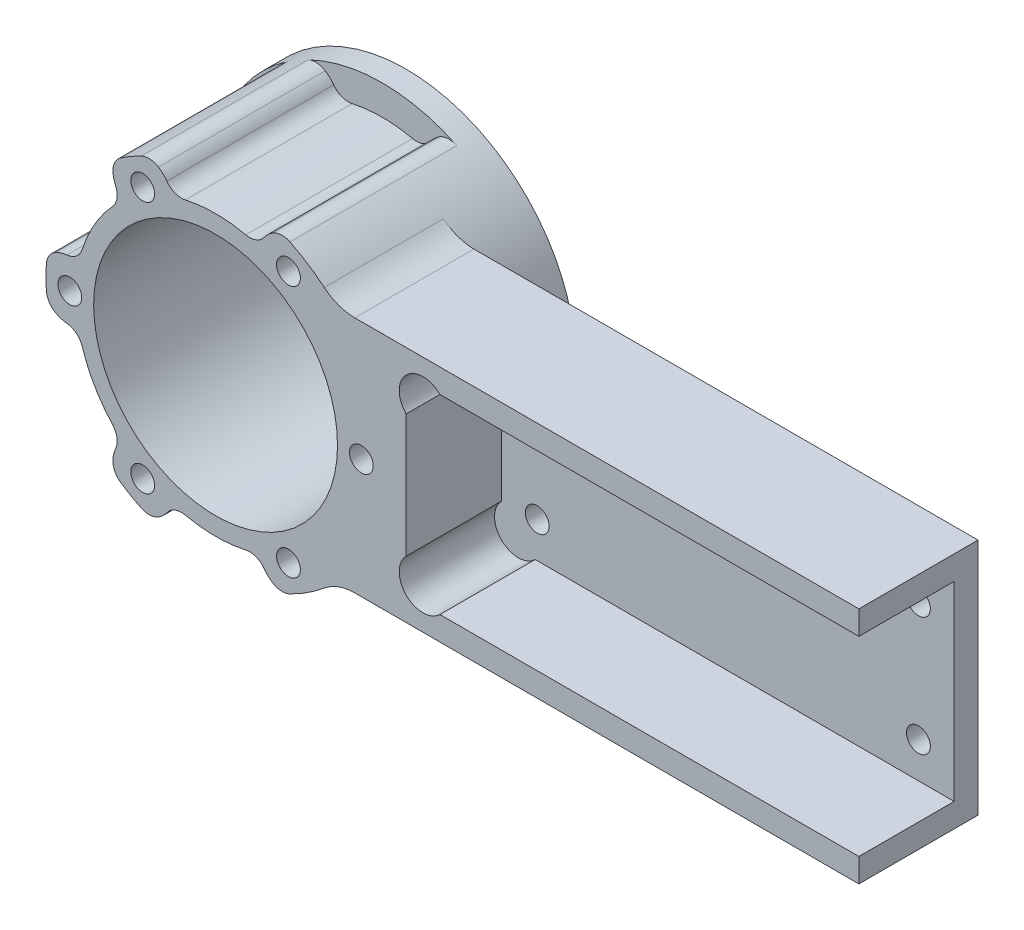
from build123d import *

# Parameters (mm, degrees)
SKETCH1_R               = 32.5
SKETCH1_W               = 120.65
SKETCH1_H               = 50.8
BOSS_EXTRUDE2_DEPTH     = 6.35
BOSS_EXTRUDE3_START     = 6.35
SKETCH1_3_R             = 32.5
BOSS_EXTRUDE3_DEPTH     = 25.4
SKETCH2_R               = 3.175
CUT_EXTRUDE1_DEPTH      = 26.4
CUT_EXTRUDE1_DEPTH_BACK = 7.35
SKETCH3_R               = 6.35
CUT_EXTRUDE2_DEPTH      = 25.4
FILLET1_R               = 12.7
SKETCH5_R               = 32.5
BOSS_EXTRUDE6_DEPTH     = 19.05
SKETCH6_R               = 32.5
SKETCH6_R_2             = 27.5
BOSS_EXTRUDE7_DEPTH     = 2.54
SKETCH9_R               = 3.175
CUT_EXTRUDE3_DEPTH      = 1
CUT_EXTRUDE3_DEPTH_BACK = 51.8
CUT_EXTRUDE4_DEPTH      = 44.45
FILLET3_R               = 4.7625


with BuildPart() as part:
    # Sketch1 → Boss-Extrude2 (new body)
    with BuildSketch(Plane.XY):
        with BuildLine():
            Line((32.171066193, 31.75), (171.45, 31.75))
            Line((171.45, 31.75), (171.45, 25.4))
            Line((171.45, 25.4), (50.8, 25.4))
            Line((50.8, 25.4), (50.8, -25.4))
            Line((50.8, -25.4), (171.45, -25.4))
            Line((171.45, -25.4), (171.45, -31.75))
            Line((171.45, -31.75), (32.171066193, -31.75))
            ThreePointArc((32.171066193, -31.75), (-45.2, 0), (32.171066193, 31.75))
        make_face()
        Circle(SKETCH1_R, mode=Mode.SUBTRACT)
        with Locations((111.125, 0)):
            Rectangle(SKETCH1_W, SKETCH1_H)
    extrude(amount=BOSS_EXTRUDE2_DEPTH)

    # Sketch1_3 → Boss-Extrude3 (add)
    with BuildSketch(Plane.XY.offset(BOSS_EXTRUDE3_START)):
        with BuildLine():
            Line((32.171066193, 31.75), (171.45, 31.75))
            Line((171.45, 31.75), (171.45, 25.4))
            Line((171.45, 25.4), (50.8, 25.4))
            Line((50.8, 25.4), (50.8, -25.4))
            Line((50.8, -25.4), (171.45, -25.4))
            Line((171.45, -25.4), (171.45, -31.75))
            Line((171.45, -31.75), (32.171066193, -31.75))
            ThreePointArc((32.171066193, -31.75), (-45.2, 0), (32.171066193, 31.75))
        make_face()
        Circle(SKETCH1_3_R, mode=Mode.SUBTRACT)
    extrude(amount=BOSS_EXTRUDE3_DEPTH)

    # Sketch2 → Cut-Extrude1 (cut, two sides)
    with BuildSketch(Plane.XY.offset(6.35)) as cut_extrude1_sk:
        with Locations((60.325, 15.875)):
            Circle(SKETCH2_R)
        with Locations((161.925, 15.875)):
            Circle(SKETCH2_R)
        with Locations((161.925, -15.875)):
            Circle(SKETCH2_R)
        with Locations((60.325, -15.875)):
            Circle(SKETCH2_R)
    extrude(amount=CUT_EXTRUDE1_DEPTH, mode=Mode.SUBTRACT)
    extrude(cut_extrude1_sk.sketch, amount=-CUT_EXTRUDE1_DEPTH_BACK, mode=Mode.SUBTRACT)

    # Sketch3 → Cut-Extrude2 (cut)
    with BuildSketch(Plane.XY.offset(31.75)):
        with Locations((55.290128061, 20.909871939)):
            Circle(SKETCH3_R)
        with Locations((55.290128061, -20.909871939)):
            Circle(SKETCH3_R)
    extrude(amount=-CUT_EXTRUDE2_DEPTH, mode=Mode.SUBTRACT)

    # Fillet1
    fillet1_edges = [part.edges().sort_by_distance(p)[0] for p in [
        (32.171066193, -31.75, 15.875),
        (32.171066193, 31.75, 15.875),
    ]]
    fillet(fillet1_edges, radius=FILLET1_R)

    # Sketch5 → Boss-Extrude6 (add)
    with BuildSketch(Plane(origin=(0, 0, 0), x_dir=(-1, 0, 0), z_dir=(0, 0, -1))):
        with BuildLine():
            ThreePointArc((-28.964426695, -34.700172712), (45.2, 0), (-28.964426695, 34.700172712))
            ThreePointArc((-28.964426695, 34.700172712), (-45.2, 0), (-28.964426695, -34.700172712))
        make_face()
        Circle(SKETCH5_R, mode=Mode.SUBTRACT)
    extrude(amount=BOSS_EXTRUDE6_DEPTH)

    # Sketch6 → Boss-Extrude7 (add)
    with BuildSketch(Plane(origin=(0, 0, -19.05), x_dir=(-1, 0, 0), z_dir=(0, 0, -1))):
        Circle(SKETCH6_R)
        Circle(SKETCH6_R_2, mode=Mode.SUBTRACT)
    extrude(amount=-BOSS_EXTRUDE7_DEPTH)

    # Sketch9 → Cut-Extrude3 (cut, two sides)
    with BuildSketch(Plane(origin=(0, 0, -19.05), x_dir=(-1, 0, 0), z_dir=(0, 0, -1))) as cut_extrude3_sk:
        with Locations((38.85, 0)):
            Circle(SKETCH9_R)
        with Locations((19.425, -33.645086937)):
            Circle(SKETCH9_R)
        with Locations((-19.425, -33.645086937)):
            Circle(SKETCH9_R)
        with Locations((-38.85, 0)):
            Circle(SKETCH9_R)
        with Locations((-19.425, 33.645086937)):
            Circle(SKETCH9_R)
        with Locations((19.425, 33.645086937)):
            Circle(SKETCH9_R)
    extrude(amount=CUT_EXTRUDE3_DEPTH, mode=Mode.SUBTRACT)
    extrude(cut_extrude3_sk.sketch, amount=-CUT_EXTRUDE3_DEPTH_BACK, mode=Mode.SUBTRACT)

    # Sketch10 → Cut-Extrude4 (cut)
    with BuildSketch(Plane.XY.offset(31.75)):
        with BuildLine():
            ThreePointArc((11.68042689, 35.384481541), (0, 37.2625), (-11.68042689, 35.384481541))
            ThreePointArc((-11.68042689, 35.384481541), (-13.931491225, 39.374420894), (-18.012469973, 41.455891324))
            ThreePointArc((-18.012469973, 41.455891324), (0, 45.2), (18.012469973, 41.455891324))
            ThreePointArc((18.012469973, 41.455891324), (13.931491225, 39.374420894), (11.68042689, 35.384481541))
        make_face()
        with BuildLine():
            ThreePointArc((-26.895620037, 36.327202244), (-27.133503141, 31.752235761), (-24.803646469, 27.807787184))
            ThreePointArc((-24.803646469, 27.807787184), (-32.270271609, 18.63125), (-36.484073359, 7.576694357))
            ThreePointArc((-36.484073359, 7.576694357), (-41.064994367, 7.622185133), (-44.90809001, 5.128689081))
            ThreePointArc((-44.90809001, 5.128689081), (-39.144348251, 22.6), (-26.895620037, 36.327202244))
        make_face()
        with BuildLine():
            ThreePointArc((-44.90809001, -5.128689081), (-41.064994367, -7.622185133), (-36.484073359, -7.576694357))
            ThreePointArc((-36.484073359, -7.576694357), (-32.270271609, -18.63125), (-24.803646469, -27.807787184))
            ThreePointArc((-24.803646469, -27.807787184), (-27.133503141, -31.752235761), (-26.895620037, -36.327202244))
            ThreePointArc((-26.895620037, -36.327202244), (-39.144348251, -22.6), (-44.90809001, -5.128689081))
        make_face()
        with BuildLine():
            ThreePointArc((-18.012469973, -41.455891324), (-13.931491225, -39.374420894), (-11.68042689, -35.384481541))
            ThreePointArc((-11.68042689, -35.384481541), (0, -37.2625), (11.68042689, -35.384481541))
            ThreePointArc((11.68042689, -35.384481541), (13.931491225, -39.374420894), (18.012469973, -41.455891324))
            ThreePointArc((18.012469973, -41.455891324), (0, -45.2), (-18.012469973, -41.455891324))
        make_face()
    extrude(amount=-CUT_EXTRUDE4_DEPTH, mode=Mode.SUBTRACT)

    # Fillet3
    fillet3_edges = [part.edges().sort_by_distance(p)[0] for p in [
        (18.012469973, -41.455891324, 15.875),
        (-18.012469973, -41.455891324, 15.875),
        (-11.68042689, -35.384481541, 9.525),
        (11.68042689, -35.384481541, 9.525),
        (-26.895620037, -36.327202244, 15.875),
        (-44.90809001, -5.128689081, 15.875),
        (-36.484073359, -7.576694357, 9.525),
        (-24.803646469, -27.807787184, 9.525),
        (-44.90809001, 5.128689081, 15.875),
        (-26.895620037, 36.327202244, 15.875),
        (-24.803646469, 27.807787184, 9.525),
        (-36.484073359, 7.576694357, 9.525),
        (-18.012469973, 41.455891324, 15.875),
        (-11.68042689, 35.384481541, 9.525),
        (11.68042689, 35.384481541, 9.525),
        (18.012469973, 41.455891324, 15.875),
    ]]
    fillet(fillet3_edges, radius=FILLET3_R)


solid = part.part
